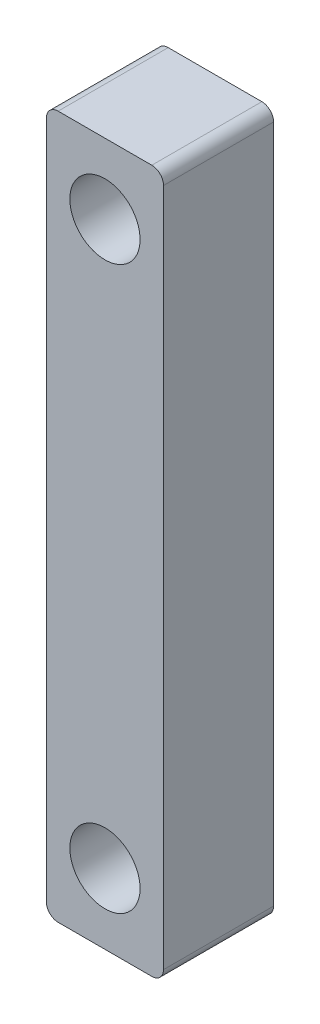
from build123d import *

# Parameters (mm, degrees)
BOSS_EXTRUDE1_DEPTH = 4.7
SKETCH2_R           = 1.5
CUT_EXTRUDE1_DEPTH  = 5.7


with BuildPart() as part:
    # Sketch1 → Boss-Extrude1 (new body)
    with BuildSketch(Plane.XY):
        with BuildLine():
            Line((0.5, 0), (4.5, 0))
            ThreePointArc((4.5, 0), (4.853553391, -0.146446609), (5, -0.5))
            Line((5, -0.5), (5, -29.5))
            ThreePointArc((5, -29.5), (4.853553391, -29.853553391), (4.5, -30))
            Line((4.5, -30), (0.5, -30))
            ThreePointArc((0.5, -30), (0.146446609, -29.853553391), (0, -29.5))
            Line((0, -29.5), (0, -0.5))
            ThreePointArc((0, -0.5), (0.146446609, -0.146446609), (0.5, 0))
        make_face()
    extrude(amount=BOSS_EXTRUDE1_DEPTH)

    # Sketch2 → Cut-Extrude1 (cut, through all)
    with BuildSketch(Plane.XY.offset(4.7)):
        with Locations((2.5, -27)):
            Circle(SKETCH2_R)
        with Locations((2.5, -3)):
            Circle(SKETCH2_R)
    extrude(amount=-CUT_EXTRUDE1_DEPTH, mode=Mode.SUBTRACT)


solid = part.part
